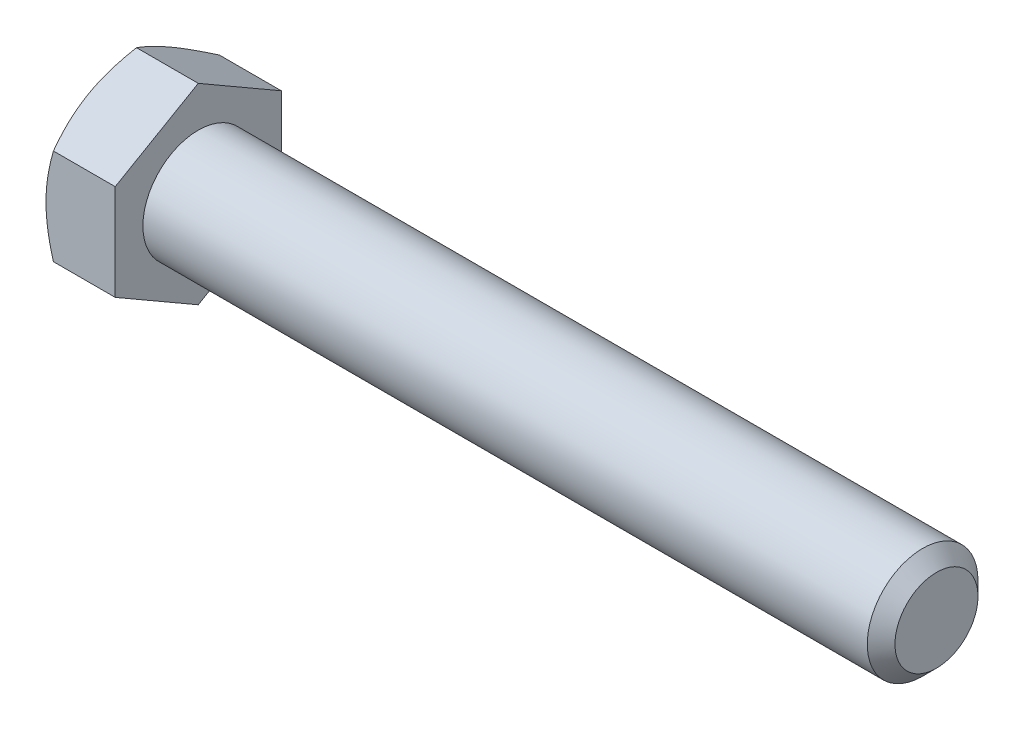
from build123d import *

# Parameters (mm, degrees)
SKETCH5_R           = 4.7625
BOSS_EXTRUDE3_DEPTH = 63.5
CHAMFER1_SIZE       = 1.190625
BOSS_EXTRUDE4_DEPTH = 5.953125
SKETCH8_OUTSIDE_W   = 274.906
SKETCH8_OUTSIDE_H   = 277.116
SKETCH8_OUTSIDE_R   = 7.14375
CUT_EXTRUDE3_DEPTH  = 70.453125
CUT_EXTRUDE3_TAPER  = 60


with BuildPart() as part:
    # Sketch5 → Boss-Extrude3 (new body)
    with BuildSketch(Plane(origin=(34.7265625, 0, 0), x_dir=(0, 0, -1), z_dir=(1, 0, 0))):
        Circle(SKETCH5_R)
    extrude(amount=-BOSS_EXTRUDE3_DEPTH)

    # Chamfer1
    chamfer1_edges = [part.edges().sort_by_distance(p)[0] for p in [
        (34.7265625, 0, 4.7625),
    ]]
    chamfer(chamfer1_edges, length=CHAMFER1_SIZE)

    # Sketch6 → Boss-Extrude4 (add)
    with BuildSketch(Plane.ZY.offset(28.7734375)):
        Polygon((7.14375, 4.124445986), (0, 8.248891971), (-7.14375, 4.124445986), (-7.14375, -4.124445986), (0, -8.248891971), (7.14375, -4.124445986), align=None)
    extrude(amount=BOSS_EXTRUDE4_DEPTH)

    # Sketch8 outside → Cut-Extrude3 (cut, through all)
    with BuildSketch(Plane.ZY.offset(34.7265625)):
        Rectangle(SKETCH8_OUTSIDE_W, SKETCH8_OUTSIDE_H)
        Circle(SKETCH8_OUTSIDE_R, mode=Mode.SUBTRACT)
    extrude(amount=-CUT_EXTRUDE3_DEPTH, taper=CUT_EXTRUDE3_TAPER, mode=Mode.SUBTRACT)


solid = part.part
